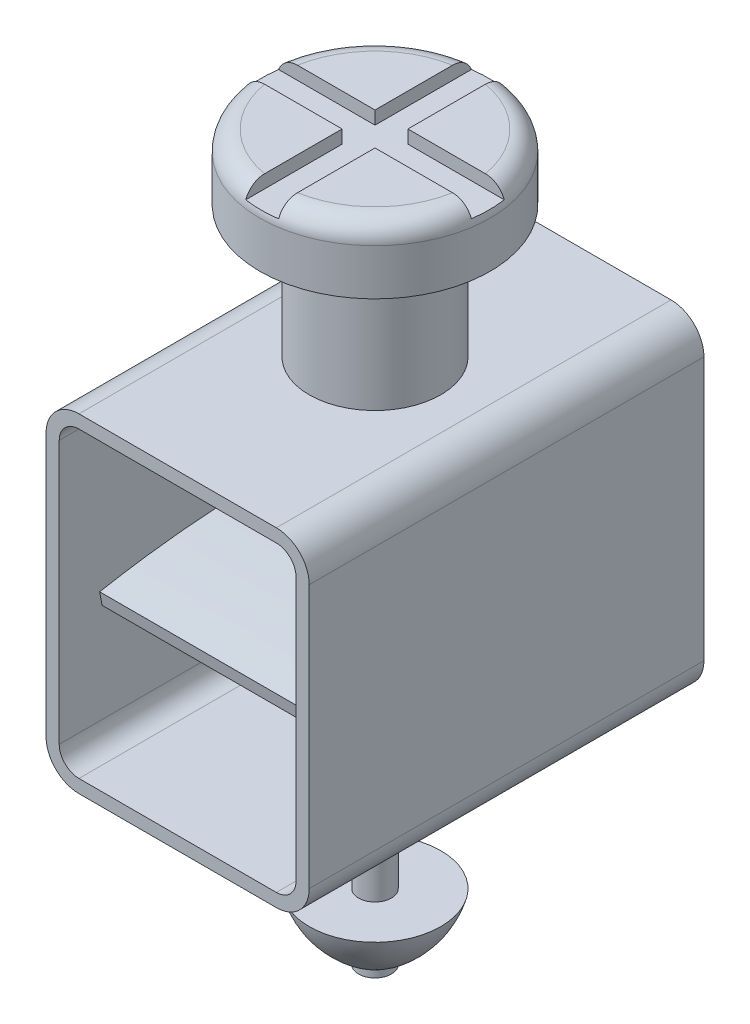
from build123d import *

# Parameters (mm, degrees)
Y_KSEKLIK_EKSTR_ZYON1_DEPTH      = 3
Y_KSEKLIK_EKSTR_ZYON1_DEPTH_BACK = 3
Y_KSEKLIK_EKSTR_ZYON7_DEPTH      = 1.5
Y_KSEKLIK_EKSTR_ZYON7_DEPTH_BACK = 1.5
Y_KSEKLIK_EKSTR_ZYON8_DEPTH      = 2
Y_KSEKLIK_EKSTR_ZYON8_DEPTH_BACK = 3
IZIM11_R                         = 1
RADYUS3_R                        = 0.3
IZIM12_R                         = 1.75
Y_KSEKLIK_EKSTR_ZYON9_DEPTH      = 1
RADYUS4_R                        = 0.3
KES_EKSTR_ZYON5_DEPTH            = 0.2
IZIM14_R                         = 0.25
Y_KSEKLIK_EKSTR_ZYON10_DEPTH     = 3


with BuildPart() as part:
    # Çizim1 → Yükseklik-Ekstrüzyon1 (new, two sides: drawn at the far end of the back side and taken through both)
    with BuildSketch(Plane.XY.offset(-Y_KSEKLIK_EKSTR_ZYON1_DEPTH_BACK)):
        with BuildLine():
            Line((-1.5, 2.5), (1.5, 2.5))
            ThreePointArc((1.5, 2.5), (1.853553391, 2.353553391), (2, 2))
            Line((2, 2), (2, -2))
            ThreePointArc((2, -2), (1.853553391, -2.353553391), (1.5, -2.5))
            Line((1.5, -2.5), (-1.5, -2.5))
            ThreePointArc((-1.5, -2.5), (-1.853553391, -2.353553391), (-2, -2))
            Line((-2, -2), (-2, 2))
            ThreePointArc((-2, 2), (-1.853553391, 2.353553391), (-1.5, 2.5))
        make_face()
        with BuildLine():
            Line((-1.8, 2), (-1.8, -2))
            ThreePointArc((-1.8, -2), (-1.712132034, -2.212132034), (-1.5, -2.3))
            Line((-1.5, -2.3), (1.5, -2.3))
            ThreePointArc((1.5, -2.3), (1.712132034, -2.212132034), (1.8, -2))
            Line((1.8, -2), (1.8, 2))
            ThreePointArc((1.8, 2), (1.712132034, 2.212132034), (1.5, 2.3))
            Line((1.5, 2.3), (-1.5, 2.3))
            ThreePointArc((-1.5, 2.3), (-1.712132034, 2.212132034), (-1.8, 2))
        make_face(mode=Mode.SUBTRACT)
    extrude(amount=Y_KSEKLIK_EKSTR_ZYON1_DEPTH + Y_KSEKLIK_EKSTR_ZYON1_DEPTH_BACK)



with BuildPart() as body_2:
    # Çizim10 → Yükseklik-Ekstrüzyon7 (new, two sides: drawn at the far end of the back side and taken through both)
    with BuildSketch(Plane(origin=(0, 0, 0), x_dir=(0, 0, -1), z_dir=(1, 0, 0)).offset(-Y_KSEKLIK_EKSTR_ZYON7_DEPTH_BACK)):
        with BuildLine():
            Line((-2.684933096, 0), (-2.648317711, -0.196619718))
            add(Edge.make_bspline(
                [(-2.648317711, -0.196619718), (-0.912612771, 0.126610857), (0.912612771, 0.126610857), (2.648317711, -0.196619718)],
                knots=[0, 0, 0, 0, 1, 1, 1, 1], degree=3))
            Line((2.648317711, -0.196619718), (2.684933096, 0))
            add(Edge.make_bspline(
                [(-2.684933096, 0), (-0.894977699, 0.333333333), (0.894977699, 0.333333333), (2.684933096, 0)],
                knots=[0, 0, 0, 0, 1, 1, 1, 1], degree=3))
        make_face()
    extrude(amount=Y_KSEKLIK_EKSTR_ZYON7_DEPTH + Y_KSEKLIK_EKSTR_ZYON7_DEPTH_BACK)


with BuildPart() as part_1:
    add(part.part)

    add(body_2.part)  # Yükseklik-Ekstrüzyon8 merges body 2
    # Çizim11 → Yükseklik-Ekstrüzyon8 (add, two sides: drawn at the far end of the back side and taken through both)
    with BuildSketch(Plane(origin=(0, 2.5, 0), x_dir=(1, 0, 0), z_dir=(0, 1, 0)).offset(-Y_KSEKLIK_EKSTR_ZYON8_DEPTH_BACK)):
        Circle(IZIM11_R)
    extrude(amount=Y_KSEKLIK_EKSTR_ZYON8_DEPTH + Y_KSEKLIK_EKSTR_ZYON8_DEPTH_BACK)

    # Radyus3
    radyus3_edges = [part_1.edges().sort_by_distance(p)[0] for p in [
        (-1, -0.5, 0),
    ]]
    fillet(radyus3_edges, radius=RADYUS3_R)

    # Çizim12 → Yükseklik-Ekstrüzyon9 (add)
    with BuildSketch(Plane(origin=(0, 4.5, 0), x_dir=(1, 0, 0), z_dir=(0, 1, 0))):
        Circle(IZIM12_R)
    extrude(amount=Y_KSEKLIK_EKSTR_ZYON9_DEPTH)

    # Radyus4
    radyus4_edges = [part_1.edges().sort_by_distance(p)[0] for p in [
        (-1.75, 5.5, 0),
    ]]
    fillet(radyus4_edges, radius=RADYUS4_R)

    # Çizim13 → Kes-Ekstrüzyon5 (cut)
    with BuildSketch(Plane(origin=(0, 5.5, 0), x_dir=(1, 0, 0), z_dir=(0, 1, 0))):
        Polygon((-0.25, -0.25), (-0.25, -2.096616873), (0.25, -2.096616873), (0.25, -0.25), (2.70967232, -0.25), (2.70967232, 0.25), (0.25, 0.25), (0.25, 2.096616873), (-0.25, 2.096616873), (-0.25, 0.25), (-2.70967232, 0.25), (-2.70967232, -0.25), align=None)
    extrude(amount=-KES_EKSTR_ZYON5_DEPTH, mode=Mode.SUBTRACT)

    # Çizim14 → Yükseklik-Ekstrüzyon10 (add)
    with BuildSketch(Plane.XZ.offset(2.5)):
        Circle(IZIM14_R)
    extrude(amount=Y_KSEKLIK_EKSTR_ZYON10_DEPTH)

    # Çizim15 → Döndür2 (revolve)
    with BuildSketch(Plane(origin=(0, 0, 0), x_dir=(0, 0, -1), z_dir=(1, 0, 0))):
        with BuildLine():
            Line((0, -5.5), (0, -4.5))
            Line((0, -4.5), (1, -4.5))
            add(Edge.make_bspline(
                [(0, -5.5), (0.812408403, -5.158653256), (1, -4.5)],
                knots=[0, 0, 0, 0.79847646, 0.79847646, 0.79847646], degree=2))
        make_face()
    revolve(axis=Axis((0, -5.5, 0), (0, 1, 0)))


solid = part_1.part
